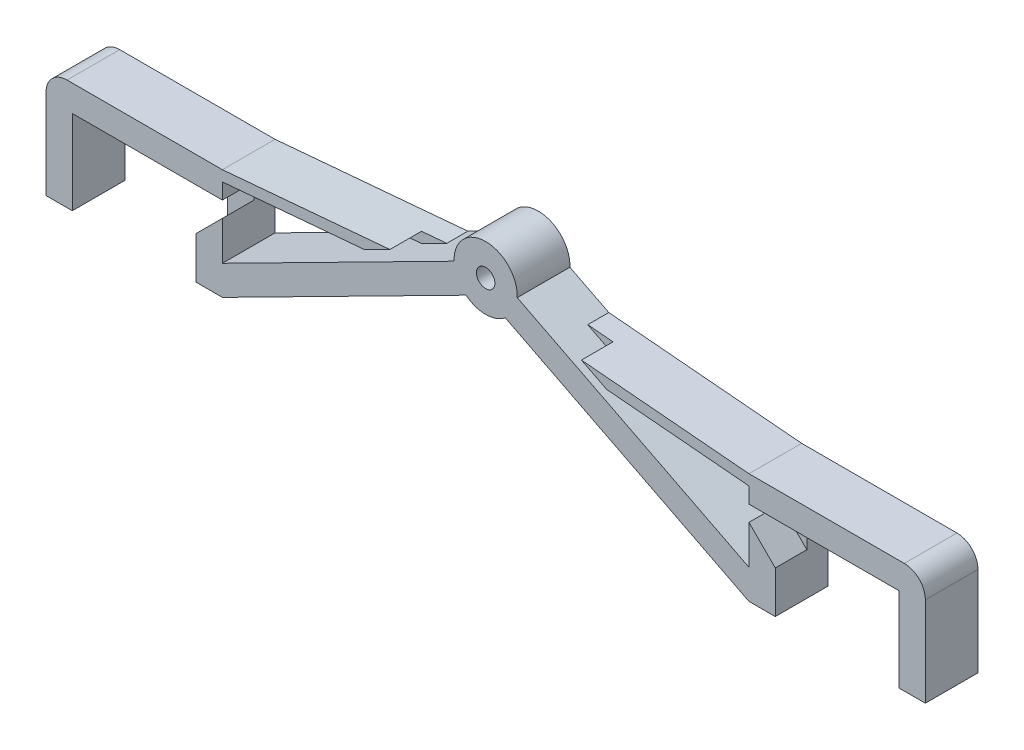
from build123d import *

# Parameters (mm, degrees)
SKICA1_R                 = 1.75
P_IDAT_VYSUNUT_M1_DEPTH  = 5
ZAOBLIT1_R               = 4
P_IDAT_VYSUNUT_M2_DEPTH  = 5
SKICA3_R                 = 1.05
ODEBRAT_VYSUNUT_M1_DEPTH = 6
ODEBRAT_VYSUNUT_M2_DEPTH = 6
ODEBRAT_VYSUNUT_M3_DEPTH = 6


with BuildPart() as part:
    # Skica1 → Přidat vysunutím1 (new body, symmetric)
    with BuildSketch(Plane.XY):
        with BuildLine():
            Line((0, 0), (0, 16))
            Line((0, 16), (23.5, 16))
            Line((23.5, 16), (23.5, 0))
            Line((23.5, 0), (28.5, 0))
            Line((28.5, 0), (74.768828107, 23.497329584))
            ThreePointArc((74.768828107, 23.497329584), (78.5, 22.196090729), (82.231171893, 23.497329584))
            Line((82.231171893, 23.497329584), (128.5, 0))
            Line((128.5, 0), (133.5, 0))
            Line((133.5, 0), (133.5, 16))
            Line((133.5, 16), (157, 16))
            Line((157, 16), (157, 0))
            Line((157, 0), (162, 0))
            Line((162, 0), (162, 21))
            Line((162, 21), (128.5, 21))
            Line((128.5, 21), (128.5, 5.607818541))
            Line((128.5, 5.607818541), (84.49517003, 27.955391095))
            ThreePointArc((84.49517003, 27.955391095), (78.5, 34.196090729), (72.50482997, 27.955391095))
            Line((72.50482997, 27.955391095), (28.5, 5.607818541))
            Line((28.5, 5.607818541), (28.5, 21))
            Line((28.5, 21), (-5, 21))
            Line((-5, 21), (-5, 0))
            Line((-5, 0), (0, 0))
        make_face()
        with Locations((78.5, 28.196090729)):
            Circle(SKICA1_R, mode=Mode.SUBTRACT)
    extrude(amount=P_IDAT_VYSUNUT_M1_DEPTH, both=True)

    # Zaoblit1
    zaoblit1_edges = [part.edges().sort_by_distance(p)[0] for p in [
        (-5, 21, 0),
        (162, 21, 0),
    ]]
    fillet(zaoblit1_edges, radius=ZAOBLIT1_R)

    # Skica2 → Přidat vysunutím2 (add, symmetric)
    with BuildSketch(Plane.XY):
        Polygon((28.5, 21), (65.117103916, 24.203581484), (60.341045967, 21.778090882), (28.5, 18.992360325), align=None)
    p_idat_vysunut_m2 = extrude(amount=P_IDAT_VYSUNUT_M2_DEPTH, both=True)

    # Zrcadlit1: Přidat vysunutím2 across plane
    add(p_idat_vysunut_m2.mirror(Plane.ZY.offset(-78.5)))

    # Skica3 → Odebrat vysunutím1 (cut)
    with BuildSketch(Plane.XZ):
        with Locations((-1.75, 0)):
            Circle(SKICA3_R)
        with Locations((25.25, 0)):
            Circle(SKICA3_R)
    odebrat_vysunut_m1 = extrude(amount=-ODEBRAT_VYSUNUT_M1_DEPTH, mode=Mode.SUBTRACT)

    # Zrcadlit2: Odebrat vysunutím1 across plane
    add(odebrat_vysunut_m1.mirror(Plane.ZY.offset(-78.5)), mode=Mode.SUBTRACT)

    # Skica4 → Odebrat vysunutím2 (cut)
    with BuildSketch(Plane.XY.offset(5)):
        Polygon((23.5, 16), (28.5, 16), (28.5, 13), (23.5, 8), align=None)
    odebrat_vysunut_m2 = extrude(amount=-ODEBRAT_VYSUNUT_M2_DEPTH, mode=Mode.SUBTRACT)

    # Zrcadlit3: Odebrat vysunutím2 across plane
    add(odebrat_vysunut_m2.mirror(Plane.ZY.offset(-78.5)), mode=Mode.SUBTRACT)

    # Skica5 → Odebrat vysunutím3 (cut)
    with BuildSketch(Plane.XY.offset(5)):
        Polygon((60.341045967, 21.778090882), (65.117103916, 24.203581484), (60.314461293, 23.783404699), (55.538403344, 21.357914097), align=None)
        Polygon((91.882896084, 24.203581484), (96.685538707, 23.783404699), (101.461596656, 21.357914097), (96.658954033, 21.778090882), align=None)
    extrude(amount=-ODEBRAT_VYSUNUT_M3_DEPTH, mode=Mode.SUBTRACT)


solid = part.part
